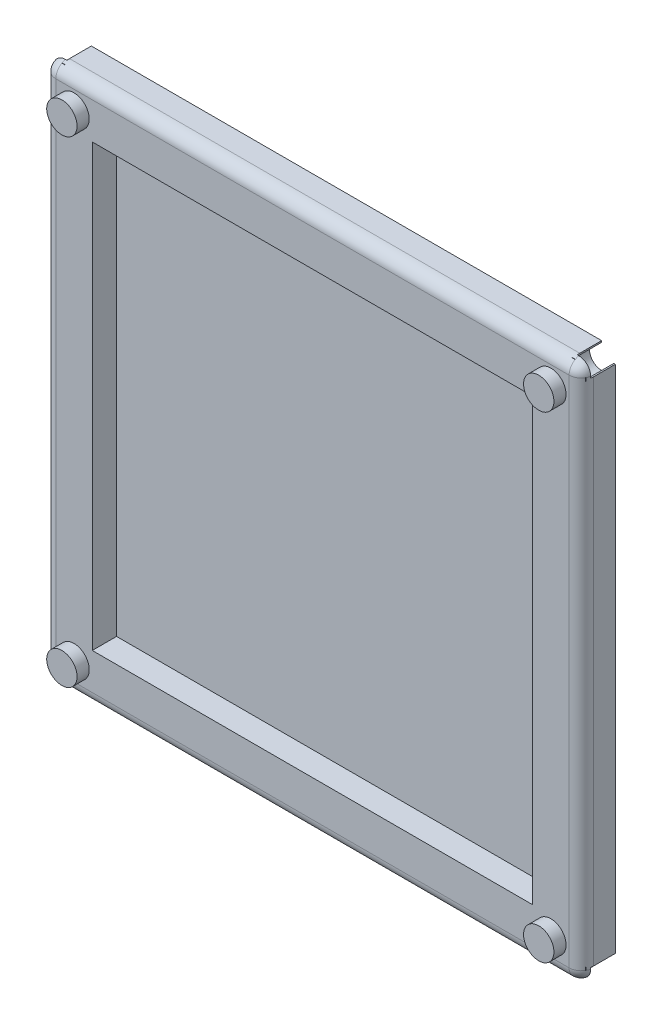
from build123d import *

# Parameters (mm, degrees)
SKETCH1_W           = 88.5
SKETCH1_H           = 88.5
SKETCH1_R           = 2
BOSS_EXTRUDE1_DEPTH = 4.6
SKETCH2_R           = 2.5
BOSS_EXTRUDE2_DEPTH = 3
SKETCH3_W           = 88.5
SKETCH3_H           = 88.5
BOSS_EXTRUDE3_DEPTH = 1
FILLET1_R           = 2
SKETCH4_W           = 2.25
SKETCH4_H           = 2.25
CUT_EXTRUDE1_DEPTH  = 4
SKETCH5_W           = 72.5
SKETCH5_H           = 72.5
CUT_EXTRUDE2_DEPTH  = 4


with BuildPart() as part:
    # Sketch1 → Boss-Extrude1 (new body)
    with BuildSketch(Plane.XY):
        with Locations((-44.25, -44.25)):
            Rectangle(SKETCH1_W, SKETCH1_H)
        with Locations((-86.25, -86.25)):
            Circle(SKETCH1_R, mode=Mode.SUBTRACT)
        with Locations((-2.25, -86.25)):
            Circle(SKETCH1_R, mode=Mode.SUBTRACT)
        with Locations((-2.25, -2.25)):
            Circle(SKETCH1_R, mode=Mode.SUBTRACT)
        with Locations((-86.25, -2.25)):
            Circle(SKETCH1_R, mode=Mode.SUBTRACT)
    extrude(amount=BOSS_EXTRUDE1_DEPTH)

    # Sketch2 → Boss-Extrude2 (add)
    with BuildSketch(Plane.XY.offset(4.6)):
        with Locations((-5, -83.5)):
            Circle(SKETCH2_R)
        with Locations((-83.5, -83.5)):
            Circle(SKETCH2_R)
        with Locations((-5, -5)):
            Circle(SKETCH2_R)
        with Locations((-83.5, -5)):
            Circle(SKETCH2_R)
    extrude(amount=BOSS_EXTRUDE2_DEPTH)

    # Sketch3 → Boss-Extrude3 (add)
    with BuildSketch(Plane.XY.offset(4.6)):
        with Locations((-44.25, -44.25)):
            Rectangle(SKETCH3_W, SKETCH3_H)
    extrude(amount=BOSS_EXTRUDE3_DEPTH)

    # Fillet1
    fillet1_edges = [part.edges().sort_by_distance(p)[0] for p in [
        (0, 0, 2.8),
        (0, -88.5, 2.8),
        (-88.5, -88.5, 2.8),
        (-88.5, 0, 2.8),
        (-88.5, -44.25, 5.6),
        (-44.25, -88.5, 5.6),
        (0, -44.25, 5.6),
        (-44.25, 0, 5.6),
    ]]
    fillet(fillet1_edges, radius=FILLET1_R)

    # Sketch4 → Cut-Extrude1 (cut)
    with BuildSketch(Plane(origin=(0, 0, 0), x_dir=(-1, 0, 0), z_dir=(0, 0, -1))):
        with Locations((87.375, -87.375)):
            Rectangle(SKETCH4_W, SKETCH4_H)
        with Locations((1.125, -87.375)):
            Rectangle(SKETCH4_W, SKETCH4_H)
        with Locations((87.375, -1.125)):
            Rectangle(SKETCH4_W, SKETCH4_H)
        with Locations((1.125, -1.125)):
            Rectangle(SKETCH4_W, SKETCH4_H)
    extrude(amount=-CUT_EXTRUDE1_DEPTH, mode=Mode.SUBTRACT)

    # Sketch5 → Cut-Extrude2 (cut)
    with BuildSketch(Plane.XY.offset(5.6)):
        with Locations((-44.25, -44.25)):
            Rectangle(SKETCH5_W, SKETCH5_H)
    extrude(amount=-CUT_EXTRUDE2_DEPTH, mode=Mode.SUBTRACT)


solid = part.part
